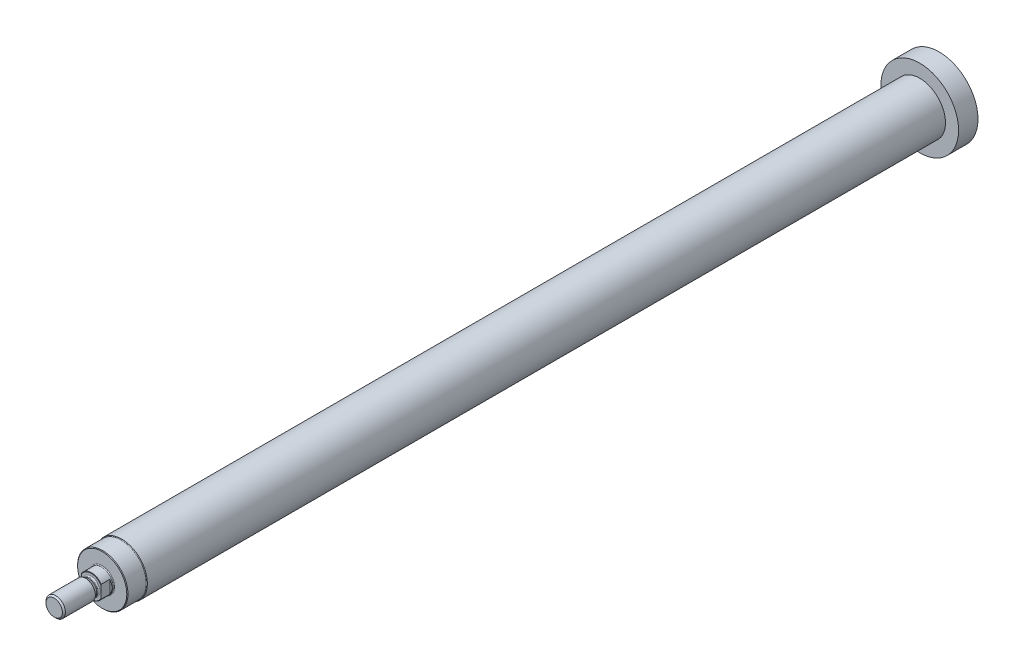
from build123d import *

# Parameters (mm, degrees)
CUT_EXTRUDE1_DEPTH = 4.7


with BuildPart() as part:
    # Sketch1 → Revolve1 (revolve)
    with BuildSketch(Plane(origin=(0, 0, 0), x_dir=(0, 0, -1), z_dir=(1, 0, 0))):
        with BuildLine():
            Line((-21.5, 0), (-21.5, 5.8))
            Line((-21.5, 5.8), (-21.3, 6))
            Line((-21.3, 6), (-16.2, 6))
            ThreePointArc((-16.2, 6), (-15.917157288, 6.117157288), (-15.8, 6.4))
            Line((-15.8, 6.4), (-15.8, 12.66))
            Line((-15.8, 12.66), (-15.5, 12.96))
            Line((-15.5, 12.96), (-6.1, 12.96))
            ThreePointArc((-6.1, 12.96), (-5.887867966, 13.047867966), (-5.8, 13.26))
            Line((-5.8, 13.26), (405, 13.26))
            Line((405, 13.26), (405, 20))
            Line((405, 20), (415, 20))
            Line((415, 20), (415, 0))
            Line((415, 0), (-21.5, 0))
        make_face()
    revolve(axis=Axis((0, 0, -415), (0, 0, 1)))

    # Sketch2 → Revolve2 (revolve)
    with BuildSketch(Plane(origin=(0, 0, 0), x_dir=(0, 0, -1), z_dir=(1, 0, 0))):
        with BuildLine():
            Line((-40.5, 0), (-40.5, 4.233))
            Line((-40.5, 4.233), (-39.733, 5))
            Line((-39.733, 5), (-24.332050808, 5))
            Line((-24.332050808, 5), (-22.739230485, 4.080384758))
            ThreePointArc((-22.739230485, 4.080384758), (-22.594521912, 4.020444504), (-22.439230485, 4))
            Line((-22.439230485, 4), (-22.1, 4))
            ThreePointArc((-22.1, 4), (-21.675735931, 4.175735931), (-21.5, 4.6))
            Line((-21.5, 4.6), (-21.5, 0))
            Line((-21.5, 0), (-40.5, 0))
        make_face()
    revolve(axis=Axis((0, 0, 21.5), (0, 0, 1)))

    # Sketch3 → Cut-Extrude1 (cut)
    with BuildSketch(Plane.XY.offset(21.5)):
        Polygon((-7, 8), (-7, -6), (-5, -6), (-5, 6), (5, 6), (5, -6), (7, -6), (7, 8), align=None)
    extrude(amount=-CUT_EXTRUDE1_DEPTH, mode=Mode.SUBTRACT)


solid = part.part
